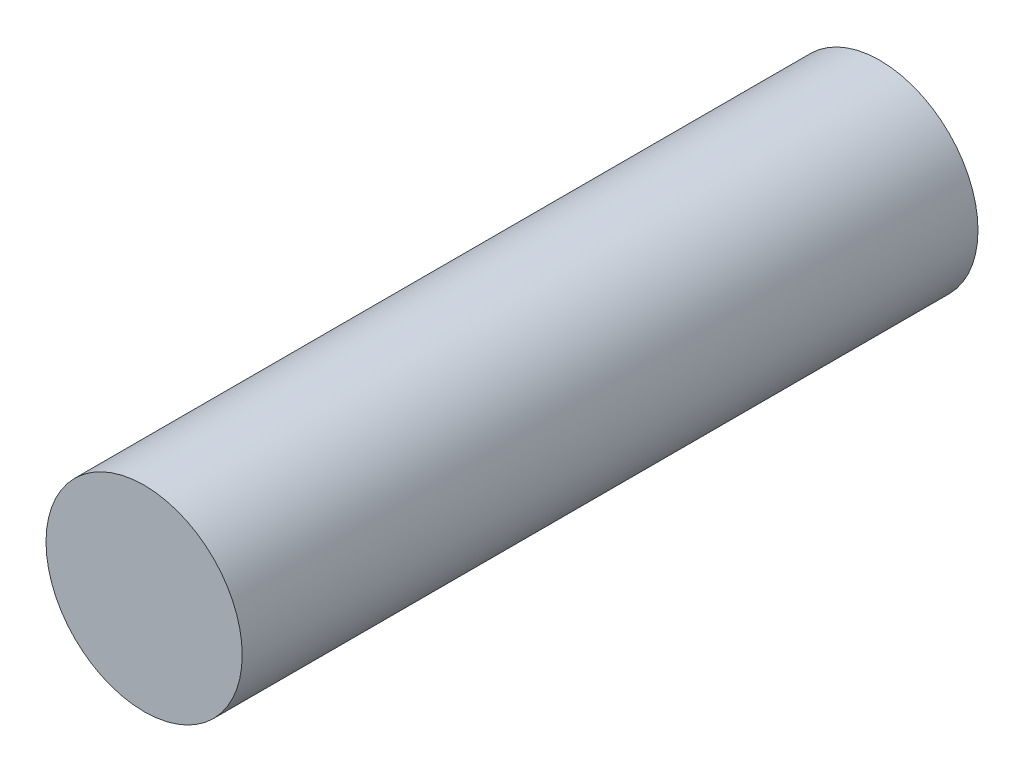
from build123d import *

# Parameters (mm, degrees)
CROQUIS1_R              = 40
SALIENTE_EXTRUIR1_DEPTH = 300


with BuildPart() as part:
    # Croquis1 → Saliente-Extruir1 (new body)
    with BuildSketch(Plane.XY):
        Circle(CROQUIS1_R)
    extrude(amount=SALIENTE_EXTRUIR1_DEPTH)


solid = part.part
